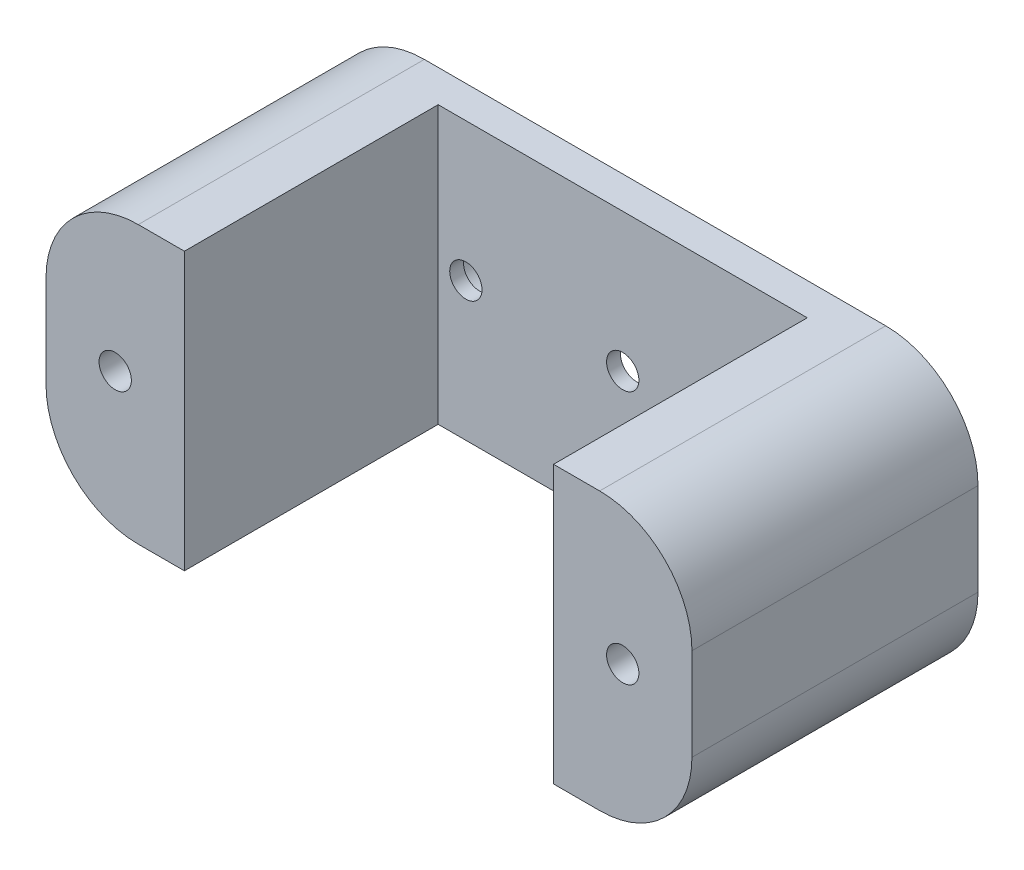
from build123d import *

# Parameters (mm, degrees)
BOSS_EXTRUDE1_DEPTH = 31
SKETCH2_W           = 40
SKETCH2_H           = 30
CUT_EXTRUDE1_DEPTH  = 27.5
SKETCH3_R           = 1.75
CUT_EXTRUDE2_DEPTH  = 32
CUT_EXTRUDE3_DEPTH  = 5
CUT_EXTRUDE4_DEPTH  = 2
SKETCH6_R           = 1.75
CUT_EXTRUDE5_DEPTH  = 32


with BuildPart() as part:
    # Sketch1 → Boss-Extrude1 (new body)
    with BuildSketch(Plane.XY):
        with BuildLine():
            Line((-25, 15), (25, 15))
            ThreePointArc((25, 15), (32.071067812, 12.071067812), (35, 5))
            Line((35, 5), (35, -5))
            ThreePointArc((35, -5), (32.071067812, -12.071067812), (25, -15))
            Line((25, -15), (-25, -15))
            ThreePointArc((-25, -15), (-32.071067812, -12.071067812), (-35, -5))
            Line((-35, -5), (-35, 5))
            ThreePointArc((-35, 5), (-32.071067812, 12.071067812), (-25, 15))
        make_face()
    extrude(amount=BOSS_EXTRUDE1_DEPTH)

    # Sketch2 → Cut-Extrude1 (cut)
    with BuildSketch(Plane.XY.offset(31)):
        Rectangle(SKETCH2_W, SKETCH2_H)
    extrude(amount=-CUT_EXTRUDE1_DEPTH, mode=Mode.SUBTRACT)

    # Sketch3 → Cut-Extrude2 (cut, through all)
    with BuildSketch(Plane.XY.offset(31)):
        with Locations((-27.5, 0)):
            Circle(SKETCH3_R)
        with Locations((27.5, 0)):
            Circle(SKETCH3_R)
    extrude(amount=-CUT_EXTRUDE2_DEPTH, mode=Mode.SUBTRACT)

    # Sketch4 → Cut-Extrude3 (cut)
    with BuildSketch(Plane(origin=(0, 0, 0), x_dir=(-1, 0, 0), z_dir=(0, 0, -1))):
        Polygon((-24.035898385, 0), (-25.767949192, 3), (-29.232050808, 3), (-30.964101615, 0), (-29.232050808, -3), (-25.767949192, -3), align=None)
        Polygon((24.035898385, 0), (25.767949192, -3), (29.232050808, -3), (30.964101615, 0), (29.232050808, 3), (25.767949192, 3), align=None)
    extrude(amount=-CUT_EXTRUDE3_DEPTH, mode=Mode.SUBTRACT)

    # Sketch5 → Cut-Extrude4 (cut)
    with BuildSketch(Plane(origin=(0, 0, 0), x_dir=(-1, 0, 0), z_dir=(0, 0, -1))):
        with BuildLine():
            Line((-17.477732777, -2.657399367), (-3.39236806, -5.189589478))
            ThreePointArc((-3.39236806, -5.189589478), (0, -6.2), (3.39236806, -5.189589478))
            Line((3.39236806, -5.189589478), (17.477732777, -2.657399367))
            ThreePointArc((17.477732777, -2.657399367), (19.7, 0), (17.477732777, 2.657399367))
            Line((17.477732777, 2.657399367), (3.39236806, 5.189589478))
            ThreePointArc((3.39236806, 5.189589478), (0, 6.2), (-3.39236806, 5.189589478))
            Line((-3.39236806, 5.189589478), (-17.477732777, 2.657399367))
            ThreePointArc((-17.477732777, 2.657399367), (-19.7, 0), (-17.477732777, -2.657399367))
        make_face()
    extrude(amount=-CUT_EXTRUDE4_DEPTH, mode=Mode.SUBTRACT)

    # Sketch6 → Cut-Extrude5 (cut, through all)
    with BuildSketch(Plane(origin=(0, 0, 0), x_dir=(-1, 0, 0), z_dir=(0, 0, -1))):
        Circle(SKETCH6_R)
        with Locations((-17, 0)):
            Circle(SKETCH6_R)
        with Locations((17, 0)):
            Circle(SKETCH6_R)
    extrude(amount=-CUT_EXTRUDE5_DEPTH, mode=Mode.SUBTRACT)


solid = part.part
